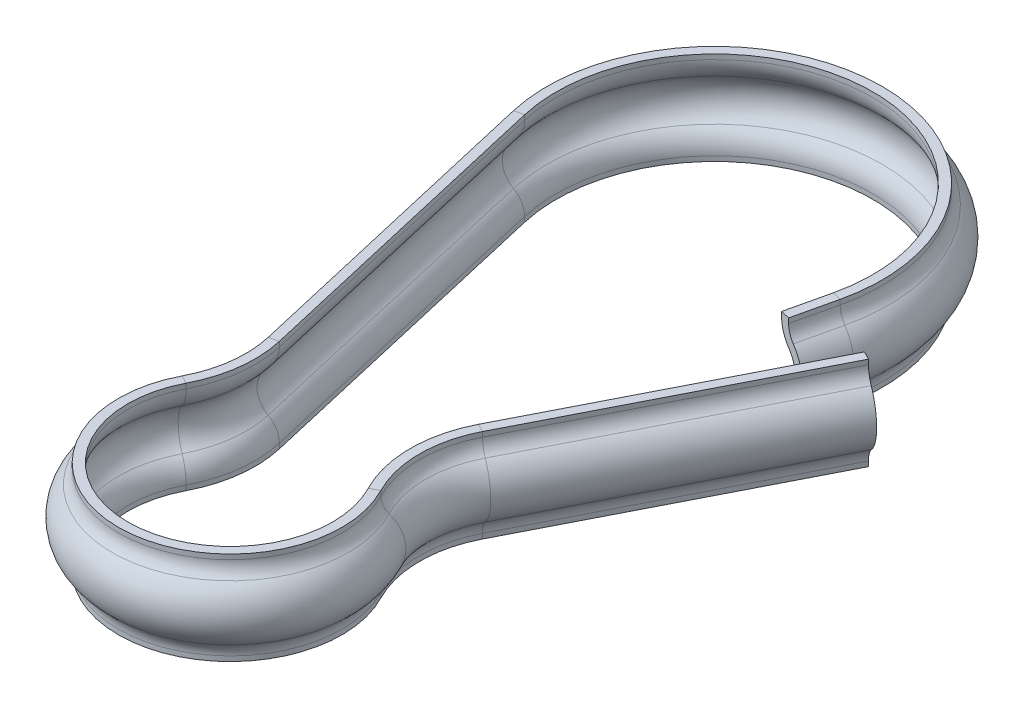
from build123d import *


with BuildPart() as part:
    # Sweep1: sweep along a path in Sketch1
    with BuildLine(Plane(origin=(0, 0, 0), x_dir=(1, 0, 0), z_dir=(0, 1, 0))) as sweep1_path:
        Line((9.224134218, 21.5), (9.743700648, 23.750489457))
        ThreePointArc((9.743700648, 23.750489457), (0, 36), (-9.743700648, 23.750489457))
        Line((-9.743700648, 23.750489457), (-5.791026476, 6.629576644))
        ThreePointArc((-5.791026476, 6.629576644), (-5.70178828, 4.882245515), (-6.220011467, 3.211145801))
        ThreePointArc((-6.220011467, 3.211145801), (0, -7), (6.220011467, 3.211145801))
        ThreePointArc((6.220011467, 3.211145801), (5.662894571, 5.491490702), (6.207844179, 7.774773871))
        Line((6.207844179, 7.774773871), (13.201196192, 21.5))
    # Sketch3 → Sweep1 (sweep)
    with BuildSketch(Plane(origin=(13.201196192, 0, -21.5), x_dir=(-0.891006524, 0, -0.4539905), z_dir=(0.4539905, 0, -0.891006524))):
        with BuildLine():
            Line((1, -2.5), (1, -2.236067977))
            ThreePointArc((1, -2.236067977), (0.912870929, -1.827819687), (0.666666667, -1.490711985))
            ThreePointArc((0.666666667, -1.490711985), (0, 0), (0.666666667, 1.490711985))
            ThreePointArc((0.666666667, 1.490711985), (0.912870929, 1.827819687), (1, 2.236067977))
            Line((1, 2.236067977), (1, 2.5))
            Line((1, 2.5), (1.5, 2.5))
            Line((1.5, 2.5), (1.5, 2.236067977))
            ThreePointArc((1.5, 2.236067977), (1.369306394, 1.623695542), (1, 1.118033989))
            ThreePointArc((1, 1.118033989), (0.5, 0), (1, -1.118033989))
            ThreePointArc((1, -1.118033989), (1.369306394, -1.623695542), (1.5, -2.236067977))
            Line((1.5, -2.236067977), (1.5, -2.5))
            Line((1.5, -2.5), (1, -2.5))
        make_face()
    sweep(path=sweep1_path.line)


solid = part.part
